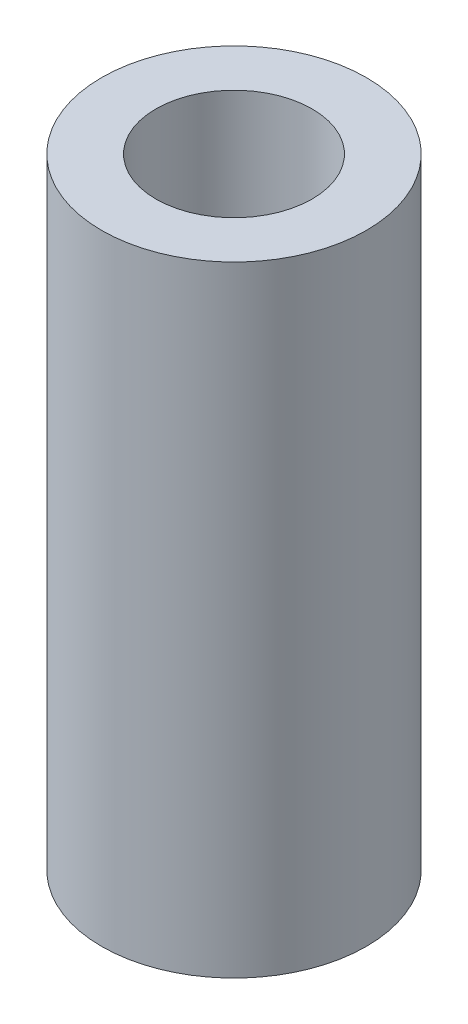
from build123d import *

# Parameters (mm, degrees)
SKETCH1_R           = 6.1
SKETCH1_R_2         = 3.6
BOSS_EXTRUDE1_DEPTH = 28.575


with BuildPart() as part:
    # Sketch1 → Boss-Extrude1 (new body)
    with BuildSketch(Plane(origin=(0, 0, 0), x_dir=(1, 0, 0), z_dir=(0, 1, 0))):
        Circle(SKETCH1_R)
        Circle(SKETCH1_R_2, mode=Mode.SUBTRACT)
    extrude(amount=BOSS_EXTRUDE1_DEPTH)


solid = part.part
